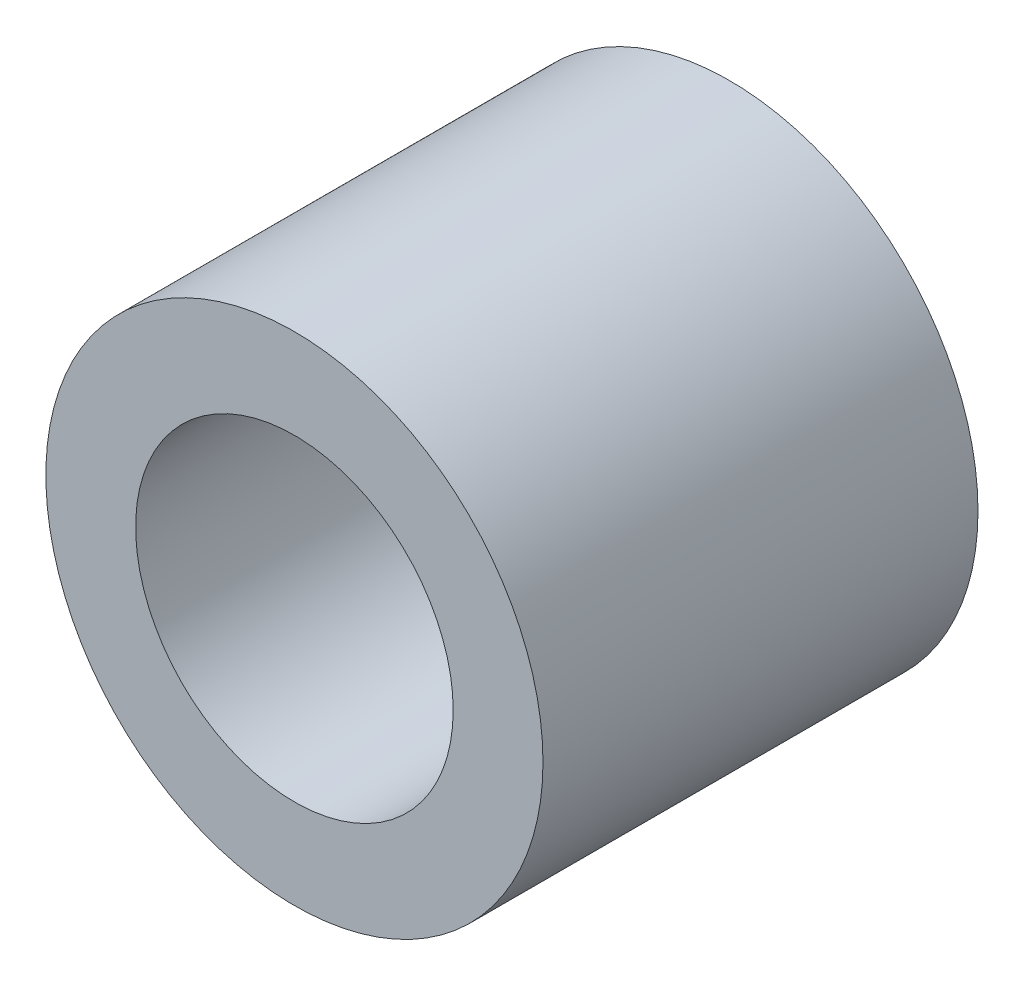
from build123d import *

# Parameters (mm, degrees)
SKETCH1_R           = 4
SKETCH1_R_2         = 2.555
BOSS_EXTRUDE1_DEPTH = 7


with BuildPart() as part:
    # Sketch1 → Boss-Extrude1 (new body)
    with BuildSketch(Plane.XY):
        Circle(SKETCH1_R)
        Circle(SKETCH1_R_2, mode=Mode.SUBTRACT)
    extrude(amount=BOSS_EXTRUDE1_DEPTH)


solid = part.part
